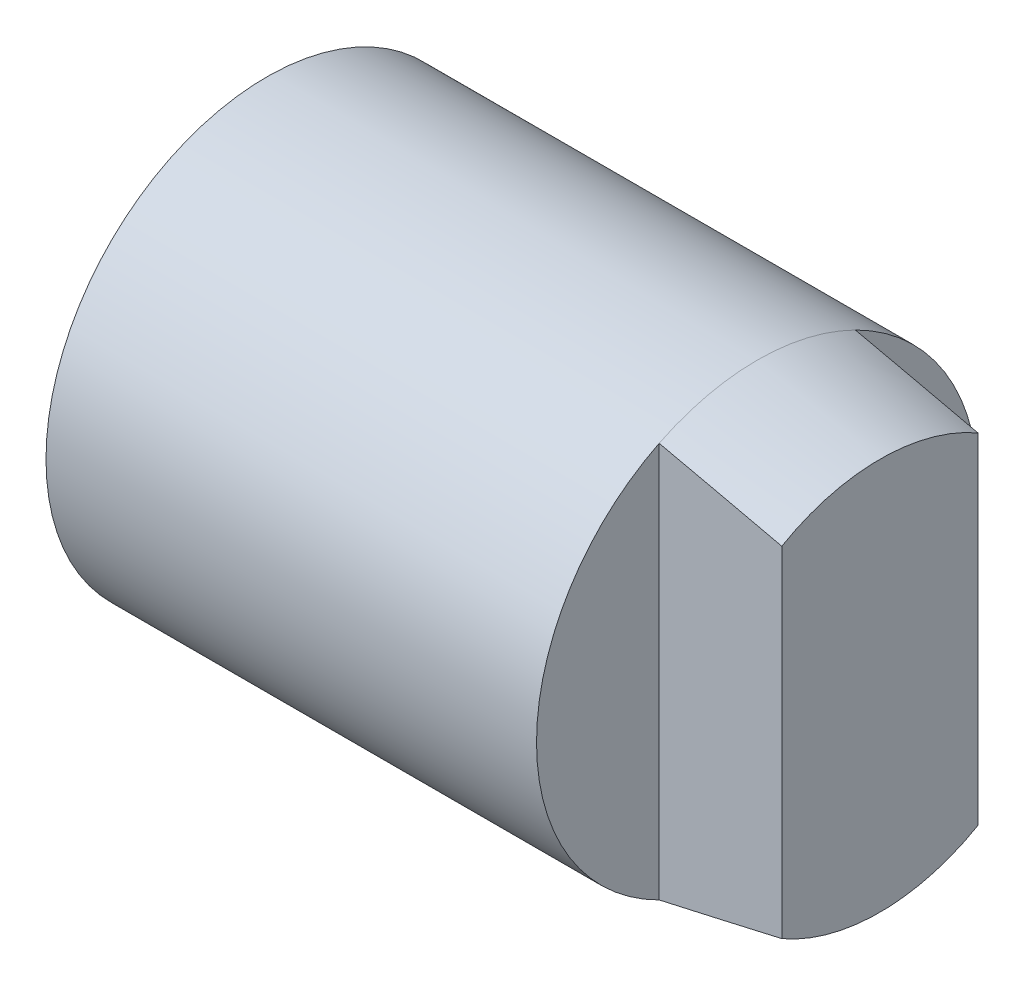
from build123d import *

# Parameters (mm, degrees)
CUT_EXTRUDE1_DEPTH = 2.5


with BuildPart() as part:
    # Sketch1 → Revolve1 (revolve)
    with BuildSketch(Plane(origin=(0, 0, 0), x_dir=(1, 0, 0), z_dir=(0, 1, 0))):
        Polygon((0, 0), (12.5, 0), (12.5, 4), (10, 4.5), (0, 4.5), align=None)
    revolve(axis=Axis((0, 0, 0), (1, 0, 0)))

    # Sketch2 → Cut-Extrude1 (cut)
    with BuildSketch(Plane(origin=(12.5, 0, 0), x_dir=(0, 0, -1), z_dir=(1, 0, 0))):
        with BuildLine():
            Line((-2, -4.031128874), (-2, 4.031128874))
            ThreePointArc((-2, 4.031128874), (-4.5, 0), (-2, -4.031128874))
        make_face()
        with BuildLine():
            Line((2, -4.031128874), (2, 4.031128874))
            ThreePointArc((2, 4.031128874), (4.5, 0), (2, -4.031128874))
        make_face()
    extrude(amount=-CUT_EXTRUDE1_DEPTH, mode=Mode.SUBTRACT)


solid = part.part
